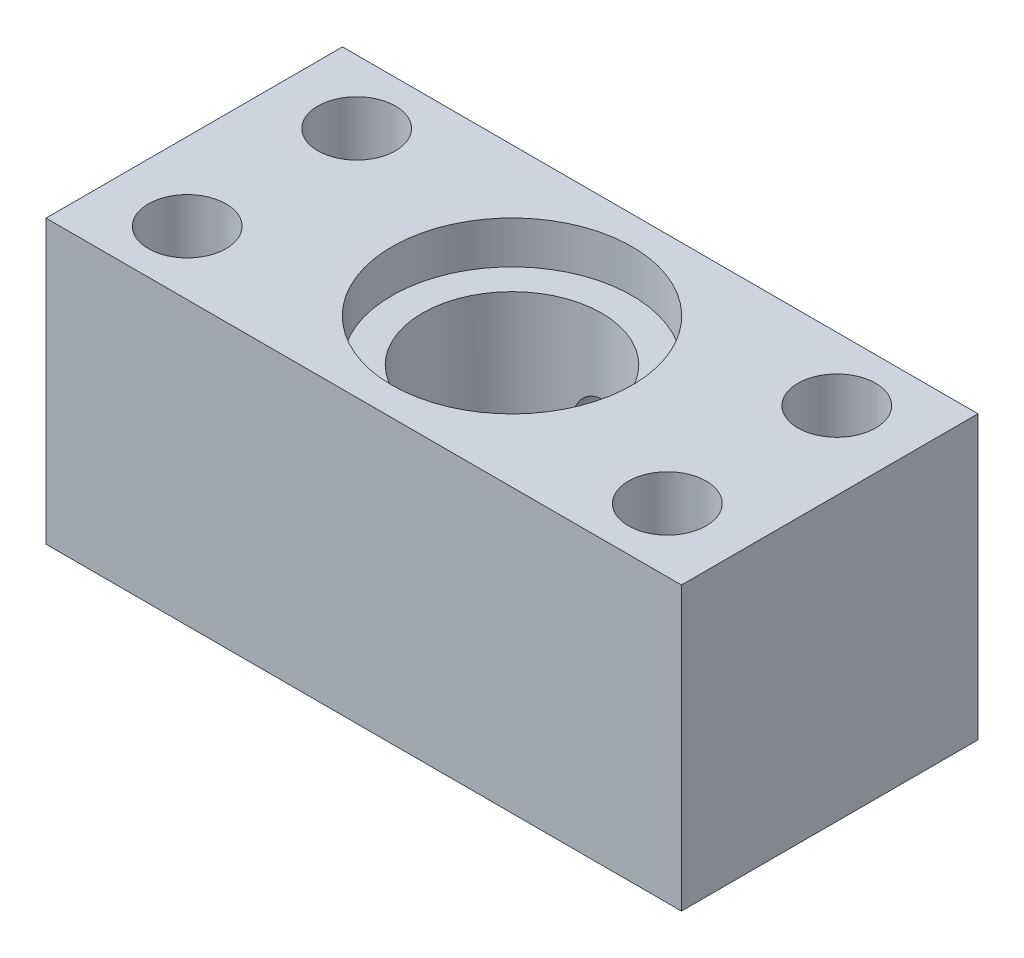
from build123d import *

# Parameters (mm, degrees)
SKETCH1_W                 = 45
SKETCH1_H                 = 21
BOSS_EXTRUDE1_DEPTH       = 20
SKETCH2_R                 = 2.75
ALIGNMENTHOLES_DEPTH      = 21
SKETCH4_R                 = 8.5
PIEZOCUT_DEPTH            = 3
F_0_535_40_TAPPED_HOLE1_D = 12.7
F_8_32_TAPPED_HOLE2_D     = 3.4544
F_8_32_TAPPED_HOLE2_DEPTH = 10
F_8_32_TAPPED_HOLE2_TIP   = 1.037806461


with BuildPart() as part:
    # Sketch1 → Boss-Extrude1 (new body)
    with BuildSketch(Plane(origin=(0, 0, 0), x_dir=(1, 0, 0), z_dir=(0, 1, 0))):
        with Locations((22.5, 10.5)):
            Rectangle(SKETCH1_W, SKETCH1_H)
    extrude(amount=BOSS_EXTRUDE1_DEPTH)

    # Sketch2 → AlignmentHoles (cut, through all)
    with BuildSketch(Plane.XZ):
        with Locations((39.5, -16.5)):
            Circle(SKETCH2_R)
        with Locations((39.5, -4.5)):
            Circle(SKETCH2_R)
        with Locations((5.5, -16.5)):
            Circle(SKETCH2_R)
        with Locations((5.5, -4.5)):
            Circle(SKETCH2_R)
    extrude(amount=-ALIGNMENTHOLES_DEPTH, mode=Mode.SUBTRACT)

    # Sketch4 → PiezoCut (cut)
    with BuildSketch(Plane(origin=(0, 20, 0), x_dir=(1, 0, 0), z_dir=(0, 1, 0))):
        with Locations((22.5, 10.5)):
            Circle(SKETCH4_R)
    extrude(amount=-PIEZOCUT_DEPTH, mode=Mode.SUBTRACT)

    # 0.535-40 Tapped Hole1 (through all)
    with Locations(Plane(origin=(0, 0, 0), x_dir=(-1, 0, 0), z_dir=(0, -1, 0))):
        with Locations((-22.5, 10.5)):
            Hole(F_0_535_40_TAPPED_HOLE1_D / 2)

    # #8-32 Tapped Hole2
    with Locations(Plane(origin=(0, 0, -21), x_dir=(-1, 0, 0), z_dir=(0, 0, -1))):
        with Locations((-22.5, 10)):
            Hole(F_8_32_TAPPED_HOLE2_D / 2, depth=F_8_32_TAPPED_HOLE2_DEPTH)
            with Locations((0, 0, -(F_8_32_TAPPED_HOLE2_DEPTH + F_8_32_TAPPED_HOLE2_TIP / 2))):  # 118° drill point
                Cone(0, F_8_32_TAPPED_HOLE2_D / 2, F_8_32_TAPPED_HOLE2_TIP, mode=Mode.SUBTRACT)


solid = part.part
